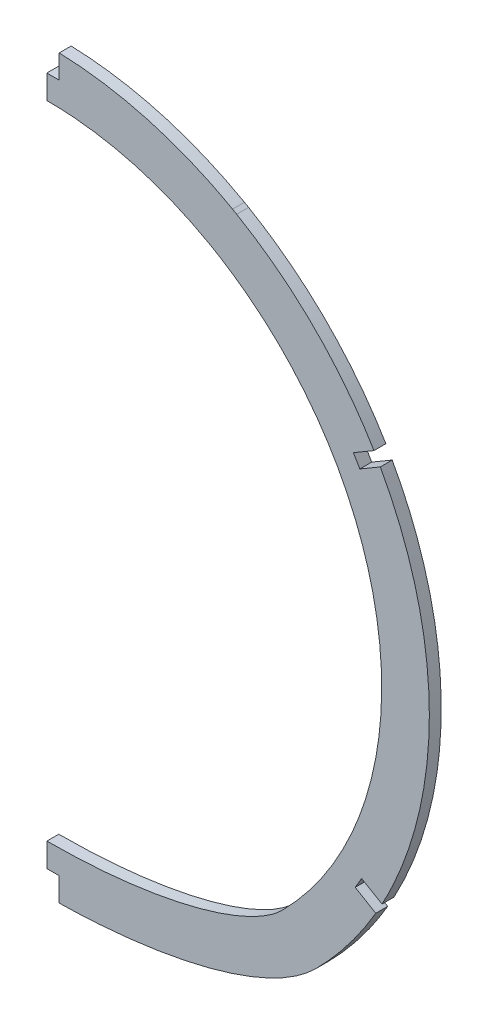
from build123d import *

# Parameters (mm, degrees)
BOSS_EXTRUDE1_DEPTH = 3.175
SKETCH3_W           = 129.389558459
SKETCH3_H           = 294.720660933
CUT_EXTRUDE1_DEPTH  = 146.946732918
CUT_EXTRUDE2_DEPTH  = 146.946411659


with BuildPart() as part:
    # Sketch2 → Boss-Extrude1 (new body)
    with BuildSketch(Plane.XY):
        with BuildLine():
            add(Edge.make_bspline(
                [(-71.677392112, -72.91043434), (-72.109242456, -72.4766599), (-72.972872043, -71.593614958), (-74.469591152, -70.002616718), (-75.837182996, -68.488043391), (-77.186084408, -66.931897067), (-78.515677479, -65.334729876), (-79.824432739, -63.69624614), (-81.54760822, -61.446428575), (-83.64161213, -58.529673548), (-85.629566809, -55.501403393), (-87.162218254, -52.997335562), (-88.285911427, -51.070131488), (-90.114728738, -47.772436811), (-92.549922179, -42.891387424), (-95.3516338, -36.175158441), (-97.806777615, -28.854790192), (-99.416568113, -22.492651102), (-100.484378106, -16.973479224), (-101.217383692, -12.115821661), (-101.805900705, -6.108471449), (-102.055561509, 1.055644647), (-101.63758347, 11.916616183), (-99.581715265, 24.703392789), (-94.947787628, 39.477591596), (-88.656512854, 52.708120751), (-80.043367163, 65.554146484), (-69.871244821, 76.755385293), (-58.636991603, 85.914826096), (-47.202028885, 92.898966836), (-35.790499648, 98.052224226), (-24.000842482, 101.716725174), (-12.029496563, 103.894248368), (-3.656941748, 104.395312689), (0.99110515, 104.372307848), (2.644688984, 104.347784008), (5.295920706, 104.255895368), (8.944129249, 104.002381094), (12.923536456, 103.566176285), (16.897932891, 102.969160213), (20.860675893, 102.210568115), (24.80503533, 101.28991654), (28.724197829, 100.207008268), (32.611281662, 98.961940132), (36.459348765, 97.555109249), (39.942943882, 96.118550993), (42.44327487, 94.981609399), (43.99462248, 94.237634049), (44.922549304, 93.78091779), (45.846607961, 93.314294304), (46.766722746, 92.837849145), (47.682656642, 92.351383169), (48.561810847, 91.873519084), (49.188310006, 91.524412896), (49.500915025, 91.348034768)],
                knots=[0, 0, 0, 0, 0.006795371, 0.013653749, 0.020575359, 0.027560428, 0.034609183, 0.041721853, 0.048898669, 0.063445664, 0.078252032, 0.085753069, 0.093319659, 0.100952039, 0.124124286, 0.148784986, 0.174947707, 0.20262677, 0.215493637, 0.232144402, 0.252599943, 0.276885796, 0.305032091, 0.363115877, 0.408011314, 0.462235121, 0.511576331, 0.564908162, 0.615597651, 0.658548959, 0.700915758, 0.742691235, 0.783870362, 0.824449909, 0.827808956, 0.831171349, 0.841278604, 0.854801757, 0.868378359, 0.882008332, 0.895691582, 0.909427999, 0.923217451, 0.937059793, 0.95095486, 0.964902468, 0.975397534, 0.978902417, 0.982410558, 0.985921952, 0.989436598, 0.99295449, 0.996475625, 1, 1, 1, 1], degree=3))
            add(Edge.make_bspline(
                [(49.500915025, 91.348034768), (49.872005924, 91.138482333), (50.241810712, 90.926750039), (50.610303013, 90.712853821)],
                knots=[0, 0, 0, 0, 1, 1, 1, 1], degree=3))
            add(Edge.make_bspline(
                [(50.610303013, 90.712853821), (51.128442093, 90.411846037), (52.167202685, 89.796039228), (53.932536969, 88.703576387), (55.579762788, 87.638711627), (57.218137155, 86.533145805), (58.847026669, 85.387425363), (60.465187486, 84.201108463), (62.61485058, 82.559008476), (65.268683437, 80.403244909), (68.38020159, 77.661045558), (71.420405526, 74.753669295), (74.379227375, 71.68115848), (77.246352549, 68.444125522), (79.542797672, 65.619898893), (81.324264236, 63.280297585), (82.635173495, 61.479754257), (83.915139631, 59.639466174), (85.682600666, 56.976700672), (87.896856718, 53.369477174), (90.462597049, 48.676901727), (92.889220315, 43.626105667), (95.132677705, 38.215723181), (97.146538959, 32.44823322), (98.88212407, 26.330630408), (100.289240179, 19.875099059), (101.25863273, 13.473856941), (101.817336128, 7.24671143), (102.015185645, 1.305015561), (101.87858065, -4.624237286), (101.39263307, -10.734726225), (100.537146292, -16.867570025), (99.329398352, -22.86381348), (97.893600846, -28.372193875), (96.656960211, -32.269847721), (95.785564151, -34.744415114), (95.0459628, -36.764317914), (93.953188789, -39.535816997), (92.43580554, -43.007047711), (90.821696456, -46.36490671), (89.118620831, -49.608230444), (87.334164726, -52.736260206), (85.475724639, -55.748623833), (83.55049497, -58.64531039), (81.56545684, -61.42664709), (79.307705413, -64.380683017), (77.436977348, -66.647222523), (76.007346494, -68.288860963), (75.29509586, -69.089727056), (74.579038656, -69.87823774), (73.859443089, -70.654502436), (73.136338858, -71.418398838), (72.317504882, -72.264736672), (71.891235125, -72.69667798), (71.678426975, -72.91043429)],
                knots=[0, 0, 0, 0, 0.010157109, 0.020393378, 0.030708694, 0.04110294, 0.051575992, 0.062127721, 0.072757993, 0.094253595, 0.116061609, 0.138180754, 0.160609666, 0.183346893, 0.206390897, 0.218027437, 0.229740057, 0.241528542, 0.253392669, 0.280162256, 0.30828042, 0.337739229, 0.368530108, 0.400643849, 0.434070605, 0.468799897, 0.504820602, 0.536144777, 0.567394405, 0.598569553, 0.629670285, 0.664058743, 0.696204476, 0.726123241, 0.753829745, 0.760691378, 0.767515904, 0.787767528, 0.807687634, 0.827278023, 0.846540474, 0.865476741, 0.88408856, 0.902377642, 0.920345676, 0.937994331, 0.961031903, 0.966703489, 0.972340071, 0.97794171, 0.983508463, 0.989040391, 0.99453755, 1, 1, 1, 1], degree=3))
            add(Edge.make_bspline(
                [(71.678426975, -72.91043429), (46.359928794, -98.341734638), (-46.358893881, -98.341734638), (-71.677392112, -72.91043434)],
                knots=[0, 0, 0, 0, 1, 1, 1, 1], degree=3, weights=[1, 1, 1, 1]))
        make_face()
        with BuildLine():
            add(Edge.make_bspline(
                [(-62.677197057, -63.950161522), (-62.895509204, -63.730876692), (-63.321725733, -63.298342375), (-64.002059554, -62.592101669), (-64.753829554, -61.794622516), (-65.703931611, -60.764569773), (-66.804574903, -59.527416198), (-68.556788175, -57.468052236), (-70.648178443, -54.835505477), (-73.811350461, -50.469012961), (-77.394544541, -44.756057433), (-82.302878117, -35.13540616), (-86.810757895, -22.360038108), (-90.354277409, -0.967371821), (-87.649941962, 26.350088977), (-73.333390238, 55.972118358), (-49.623996274, 78.708841275), (-24.487235723, 89.383519301), (-3.090994932, 92.115890306), (13.038963103, 91.197514401), (26.120286031, 87.996586306), (34.879374941, 84.524845656), (39.102105625, 82.510352052), (41.214271269, 81.410816796), (42.347028641, 80.797644792), (42.959233617, 80.456937494), (43.258169219, 80.288282027)],
                knots=[0, 0, 0, 0, 0.003906217, 0.007812434, 0.01171865, 0.015624867, 0.023437301, 0.031249734, 0.046874602, 0.062499469, 0.093749203, 0.124998938, 0.187498407, 0.249997875, 0.374996813, 0.499995751, 0.624994688, 0.749993626, 0.812493095, 0.874992564, 0.937492033, 0.968741767, 0.984366634, 0.992179068, 0.996085285, 0.999991501, 0.999991501, 0.999991501, 0.999991501], degree=3))
            add(Edge.make_bspline(
                [(43.258169219, 80.288282027), (43.339663738, 80.24226006), (43.502520945, 80.149972739), (43.746371392, 80.01083423), (43.989796594, 79.870982545), (44.151786326, 79.777278604), (44.232713854, 79.73030574)],
                knots=[0.002022438, 0.002022438, 0.002022438, 0.002022438, 0.251013535, 0.500004632, 0.748995729, 0.997986827, 0.997986827, 0.997986827, 0.997986827], degree=3))
            add(Edge.make_bspline(
                [(44.232713854, 79.73030574), (44.58444416, 79.525959484), (45.259622085, 79.127643656), (46.415361761, 78.422292298), (47.573803007, 77.692810893), (49.007921659, 76.758403592), (50.804832808, 75.530634538), (53.607223777, 73.493209173), (57.003409969, 70.790302329), (64.764138566, 63.842060668), (74.853642347, 51.769295456), (84.311822541, 33.000711524), (89.302574517, 12.581832114), (89.594071681, -8.463887057), (85.167338267, -29.022546245), (78.471156755, -43.288686452), (72.737789819, -52.004533398), (70.145497848, -55.492337454), (67.954788222, -58.18874646), (66.537169113, -59.834423786), (65.376799992, -61.124092609), (64.636118066, -61.923784826), (64.04885936, -62.544039678), (63.540759488, -63.072130947), (63.065749199, -63.559376825), (62.8132246, -63.814567336), (62.678231924, -63.950161468)],
                knots=[1.4601e-05, 1.4601e-05, 1.4601e-05, 1.4601e-05, 0.007826987, 0.015639373, 0.023451759, 0.031264145, 0.046888916, 0.062513688, 0.093763232, 0.125012776, 0.250010951, 0.375009125, 0.5000073, 0.625005475, 0.75000365, 0.875001825, 0.906251369, 0.937500913, 0.953125684, 0.968750456, 0.976562842, 0.984375228, 0.988281421, 0.992187614, 0.996093807, 1, 1, 1, 1], degree=3))
            add(Edge.make_bspline(
                [(62.678231924, -63.950161468), (62.442110433, -64.187331736), (61.973465348, -64.632177633), (60.848308103, -65.594894105), (59.178943877, -66.825880953), (56.737455869, -68.325151322), (52.942333804, -70.28884928), (47.260951473, -72.599488515), (39.221466424, -74.977986937), (30.229046438, -76.880115217), (17.304785319, -78.721740765), (0.000517457, -79.658688067), (-17.303750406, -78.721740765), (-30.228011525, -76.880115217), (-39.22043151, -74.977986937), (-47.25991656, -72.599488515), (-52.941298891, -70.28884928), (-56.736420955, -68.325151322), (-59.177908963, -66.825880953), (-60.84727319, -65.594894105), (-61.972430435, -64.632177633), (-62.441075519, -64.187331736), (-62.677197057, -63.950161522)],
                knots=[0, 0, 0, 0, 0.015625, 0.03125, 0.0625, 0.09375, 0.125, 0.1875, 0.25, 0.3125, 0.375, 0.5, 0.625, 0.6875, 0.75, 0.8125, 0.875, 0.90625, 0.9375, 0.96875, 0.984375, 1, 1, 1, 1], degree=3))
        make_face(mode=Mode.SUBTRACT)
    extrude(amount=-BOSS_EXTRUDE1_DEPTH)

    # Sketch3 → Cut-Extrude1 (cut, through all)
    with BuildSketch(Plane(origin=(0, 0, 0), x_dir=(0, 0, -1), z_dir=(1, 0, 0))):
        with Locations((3.684090068, 10.698040846)):
            Rectangle(SKETCH3_W, SKETCH3_H)
    extrude(amount=-CUT_EXTRUDE1_DEPTH, mode=Mode.SUBTRACT)

    # Sketch4 → Cut-Extrude2 (cut, through all)
    with BuildSketch(Plane(origin=(0, 0, -3.175), x_dir=(-1, 0, 0), z_dir=(0, 0, -1))):
        with BuildLine():
            Line((-3.302, 104.321166234), (-3.302, 98.02520294))
            Line((-3.302, 98.02520294), (0, 98.02520294))
            Line((0, 98.02520294), (0, 104.375573917))
            add(Edge.make_bspline(
                [(0, 104.375573917), (-0.000172469, 104.37557392), (-0.330448207, 104.375577674), (-0.99110515, 104.372307848), (-2.091699586, 104.355985239), (-2.862053013, 104.335669178), (-3.302, 104.321166234)],
                knots=[0.824448154, 0.824448154, 0.824448154, 0.824448154, 0.824449909, 0.827808956, 0.831171349, 0.835650773, 0.835650773, 0.835650773, 0.835650773], degree=3))
        make_face()
        with BuildLine():
            Line((-81.722062158, 51.245774998), (-87.20353155, 54.462689564))
            add(Edge.make_bspline(
                [(-87.20353155, 54.462689564), (-87.409764615, 54.116825858), (-87.980908871, 53.146205529), (-88.536224889, 52.166411833), (-88.886379398, 51.533314306)],
                knots=[0.273809587, 0.273809587, 0.273809587, 0.273809587, 0.280162256, 0.291575893, 0.291575893, 0.291575893, 0.291575893], degree=3))
            Line((-88.886379398, 51.533314306), (-83.431923254, 48.332253027))
            Line((-83.431923254, 48.332253027), (-81.722062158, 51.245774998))
        make_face()
        with BuildLine():
            Line((-83.903498529, -45.955037742), (-89.344854456, -49.1484109))
            add(Edge.make_bspline(
                [(-89.344854456, -49.1484109), (-89.260356438, -49.304562283), (-88.721792123, -50.293767486), (-88.167188658, -51.274187164), (-87.688792998, -52.09350631)],
                knots=[0.843739183, 0.843739183, 0.843739183, 0.843739183, 0.846540474, 0.861509714, 0.861509714, 0.861509714, 0.861509714], degree=3))
            Line((-87.688792998, -52.09350631), (-82.193637427, -48.868559709))
            Line((-82.193637427, -48.868559709), (-83.903498529, -45.955037742))
        make_face()
        with BuildLine():
            Line((0, -91.983909557), (0, -85.633909146))
            Line((0, -85.633909146), (-3.302, -85.633909146))
            Line((-3.302, -85.633909146), (-3.302, -91.957368592))
            add(Edge.make_bspline(
                [(-3.302, -91.957368592), (-2.201916568, -91.975065341), (-1.100958215, -91.983912329), (0, -91.983909557)],
                knots=[0.481348514, 0.481348514, 0.481348514, 0.481348514, 0.500002923, 0.500002923, 0.500002923, 0.500002923], degree=3))
        make_face()
    extrude(amount=-CUT_EXTRUDE2_DEPTH, mode=Mode.SUBTRACT)


solid = part.part
